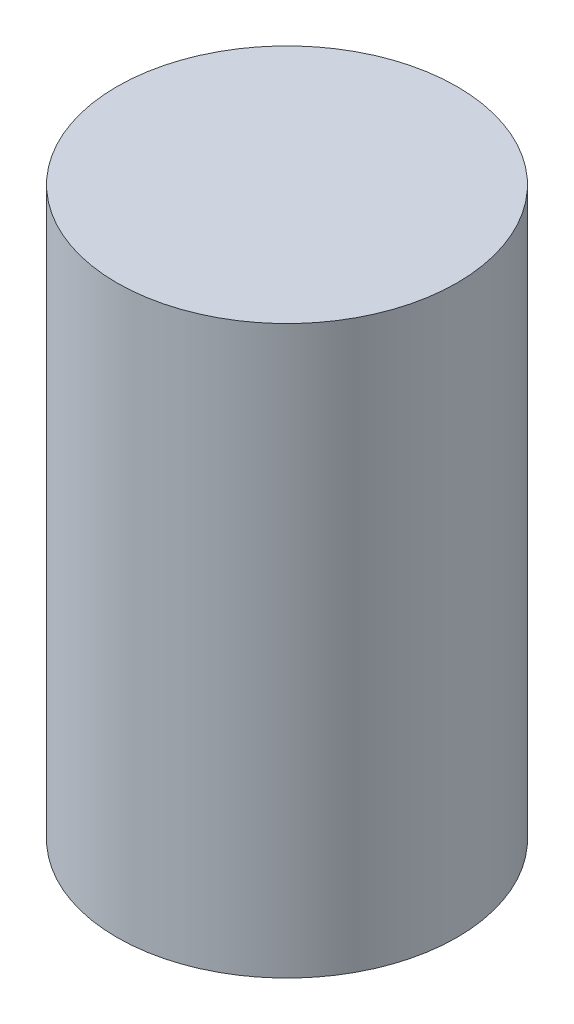
from build123d import *

# Parameters (mm, degrees)
SKETCH1_R           = 1.5
BOSS_EXTRUDE1_DEPTH = 2.5


with BuildPart() as part:
    # Sketch1 → Boss-Extrude1 (new body, symmetric)
    with BuildSketch(Plane(origin=(0, 0, 0), x_dir=(1, 0, 0), z_dir=(0, 1, 0))):
        Circle(SKETCH1_R)
    extrude(amount=BOSS_EXTRUDE1_DEPTH, both=True)


solid = part.part
